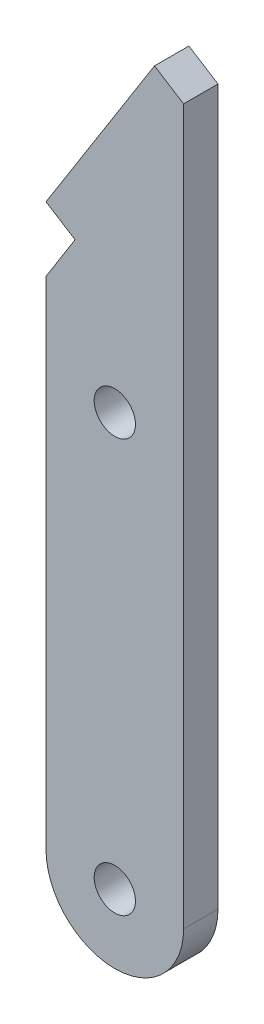
from build123d import *

# Parameters (mm, degrees)
CROQUIS1_R              = 1.5
SALIENTE_EXTRUIR1_DEPTH = 2.5


with BuildPart() as part:
    # Croquis1 → Saliente-Extruir1 (new body)
    with BuildSketch(Plane.XY):
        with BuildLine():
            Line((-5, 36.080727307), (-5, 0))
            ThreePointArc((-5, 0), (0, -5), (5, 0))
            Line((5, 0), (5, 51.928629296))
            Line((5, 51.928629296), (2.885723707, 53.262734147))
            Line((2.885723707, 53.262734147), (-5, 40.765516506))
            Line((-5, 40.765516506), (-2.885723707, 39.431411654))
            Line((-2.885723707, 39.431411654), (-5, 36.080727307))
        make_face()
        Circle(CROQUIS1_R, mode=Mode.SUBTRACT)
        with Locations((0, 30)):
            Circle(CROQUIS1_R, mode=Mode.SUBTRACT)
    extrude(amount=SALIENTE_EXTRUIR1_DEPTH)


solid = part.part
